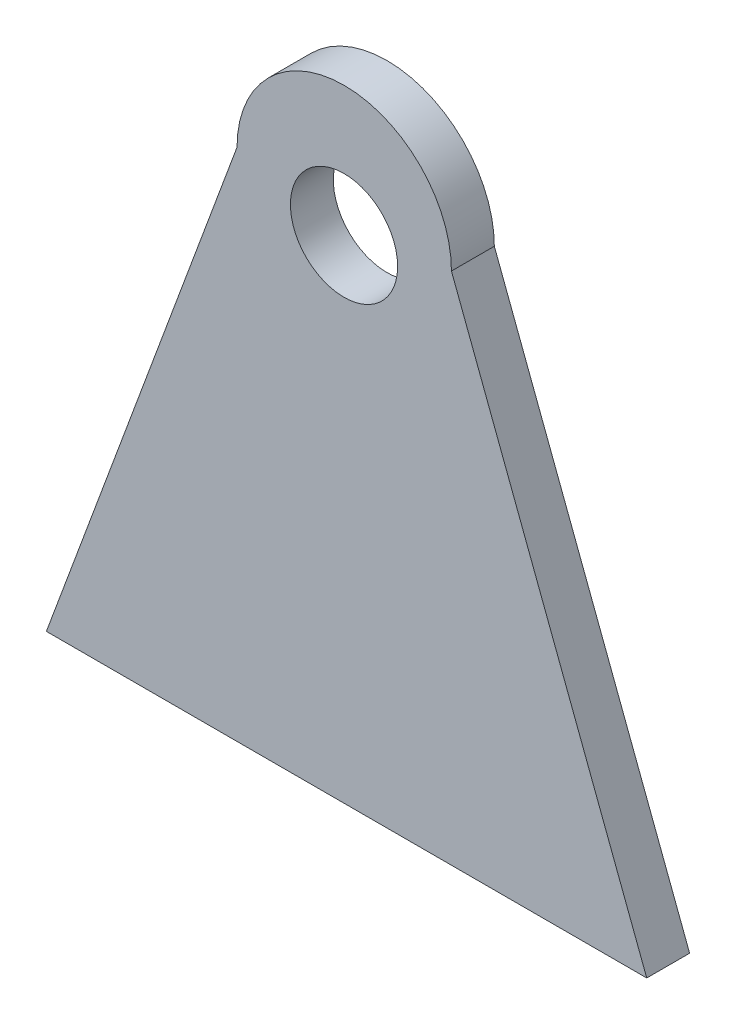
from build123d import *

# Parameters (mm, degrees)
SKETCH1_R           = 50
BOSS_EXTRUDE2_DEPTH = 20
SKETCH2_R           = 25
CUT_EXTRUDE1_DEPTH  = 20


with BuildPart() as part:
    # Sketch1 → Boss-Extrude2 (new body)
    with BuildSketch(Plane.XY):
        with BuildLine():
            Line((88.917270049, 240), (0, 0))
            Line((0, 0), (280, 0))
            Line((280, 0), (188.917270049, 240))
            ThreePointArc((188.917270049, 240), (138.917270049, 190), (88.917270049, 240))
        make_face()
        with Locations((138.917270049, 240)):
            Circle(SKETCH1_R)
    extrude(amount=BOSS_EXTRUDE2_DEPTH)

    # Sketch2 → Cut-Extrude1 (cut)
    with BuildSketch(Plane.XY.offset(20)):
        with Locations((138.81476789, 229.349018501)):
            Circle(SKETCH2_R)
    extrude(amount=-CUT_EXTRUDE1_DEPTH, mode=Mode.SUBTRACT)


solid = part.part
